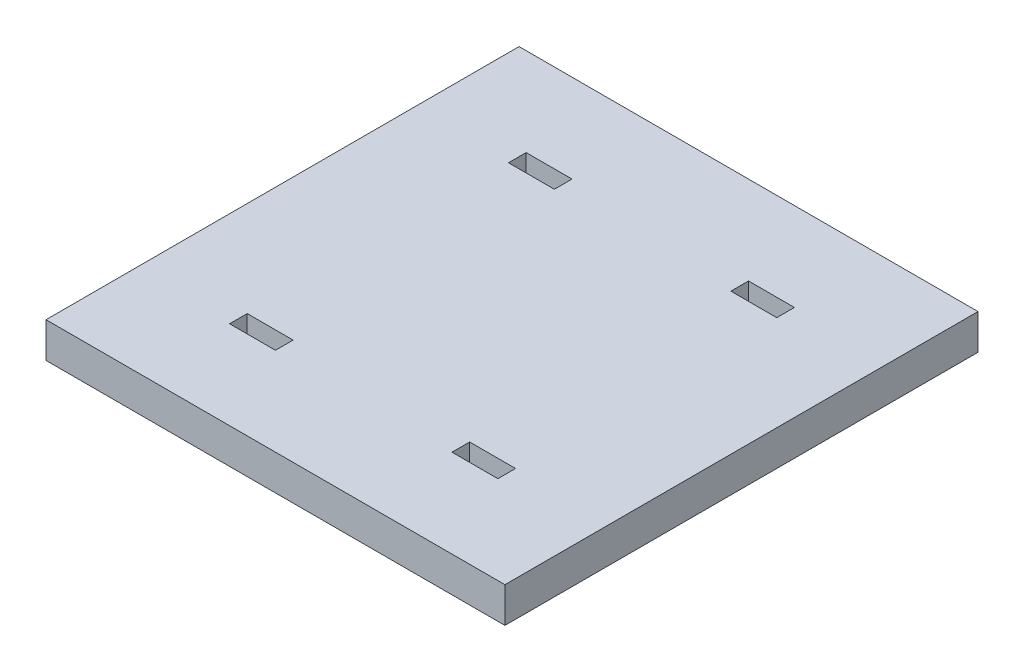
from build123d import *

# Parameters (mm, degrees)
CROQUIS1_W              = 130
CROQUIS1_H              = 134
CROQUIS1_W_2            = 13
CROQUIS1_H_2            = 5
SALIENTE_EXTRUIR1_DEPTH = 10


with BuildPart() as part:
    # Croquis1 → Saliente-Extruir1 (new body)
    with BuildSketch(Plane(origin=(0, 0, 0), x_dir=(1, 0, 0), z_dir=(0, 1, 0))):
        with Locations((65, 67)):
            Rectangle(CROQUIS1_W, CROQUIS1_H)
        with Locations((33.5, 106.5)):
            Rectangle(CROQUIS1_W_2, CROQUIS1_H_2, mode=Mode.SUBTRACT)
        with Locations((33.5, 27.5)):
            Rectangle(CROQUIS1_W_2, CROQUIS1_H_2, mode=Mode.SUBTRACT)
        with Locations((96.5, 27.5)):
            Rectangle(CROQUIS1_W_2, CROQUIS1_H_2, mode=Mode.SUBTRACT)
        with Locations((96.5, 106.5)):
            Rectangle(CROQUIS1_W_2, CROQUIS1_H_2, mode=Mode.SUBTRACT)
    extrude(amount=SALIENTE_EXTRUIR1_DEPTH)


solid = part.part
